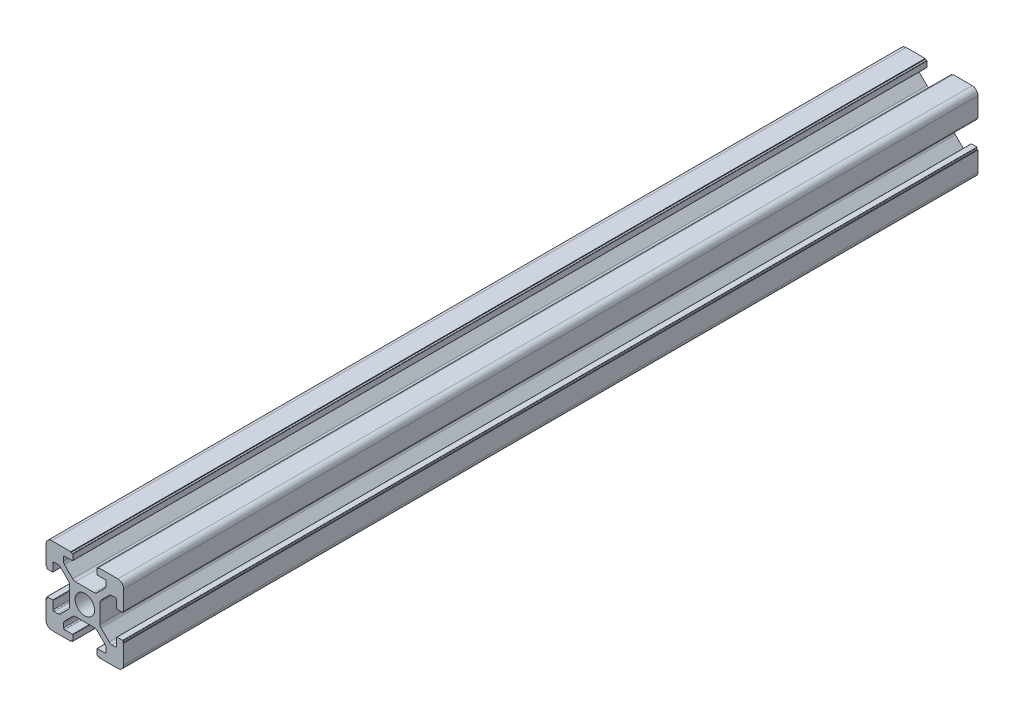
from build123d import *

# Parameters (mm, degrees)
SKETCH_1_R          = 2.5
EXTRUDE_1_DEPTH     = 220
FILLET_1_R          = 1.5
SKETCH_2_R          = 2
CUT_EXTRUDE_1_DEPTH = 21


with BuildPart() as part:
    # 草图1 → 凸台-拉伸1 (new body)
    with BuildSketch(Plane.XY):
        with BuildLine():
            Line((20, 13.6), (20, 20))
            Line((20, 20), (13.6, 20))
            Line((13.6, 20), (13.6, 19.8))
            Line((13.6, 19.8), (13.2, 19.8))
            ThreePointArc((13.2, 19.8), (13.129289322, 19.770710678), (13.1, 19.7))
            Line((13.1, 19.7), (13.1, 18.3))
            ThreePointArc((13.1, 18.3), (13.129289322, 18.229289322), (13.2, 18.2))
            Line((13.2, 18.2), (15.2, 18.2))
            ThreePointArc((15.2, 18.2), (15.412132034, 18.112132034), (15.5, 17.9))
            Line((15.5, 17.9), (15.5, 16.974873734))
            ThreePointArc((15.5, 16.974873734), (15.423879533, 16.592190302), (15.207106781, 16.267766953))
            Line((15.207106781, 16.267766953), (13.132233047, 14.192893219))
            ThreePointArc((13.132233047, 14.192893219), (12.807809698, 13.976120467), (12.425126266, 13.9))
            Line((12.425126266, 13.9), (7.574873734, 13.9))
            ThreePointArc((7.574873734, 13.9), (7.192190302, 13.976120467), (6.867766953, 14.192893219))
            Line((6.867766953, 14.192893219), (4.792893219, 16.267766953))
            ThreePointArc((4.792893219, 16.267766953), (4.576120467, 16.592190302), (4.5, 16.974873734))
            Line((4.5, 16.974873734), (4.5, 17.9))
            ThreePointArc((4.5, 17.9), (4.587867966, 18.112132034), (4.8, 18.2))
            Line((4.8, 18.2), (6.8, 18.2))
            ThreePointArc((6.8, 18.2), (6.870710678, 18.229289322), (6.9, 18.3))
            Line((6.9, 18.3), (6.9, 19.7))
            ThreePointArc((6.9, 19.7), (6.870710678, 19.770710678), (6.8, 19.8))
            Line((6.8, 19.8), (6.4, 19.8))
            Line((6.4, 19.8), (6.4, 20))
            Line((6.4, 20), (0, 20))
            Line((0, 20), (0, 13.6))
            Line((0, 13.6), (0.2, 13.6))
            Line((0.2, 13.6), (0.2, 13.2))
            ThreePointArc((0.2, 13.2), (0.229289322, 13.129289322), (0.3, 13.1))
            Line((0.3, 13.1), (1.7, 13.1))
            ThreePointArc((1.7, 13.1), (1.770710678, 13.129289322), (1.8, 13.2))
            Line((1.8, 13.2), (1.8, 15.2))
            ThreePointArc((1.8, 15.2), (1.887867966, 15.412132034), (2.1, 15.5))
            Line((2.1, 15.5), (3.025126266, 15.5))
            ThreePointArc((3.025126266, 15.5), (3.407809698, 15.423879533), (3.732233047, 15.207106781))
            Line((3.732233047, 15.207106781), (5.807106781, 13.132233047))
            ThreePointArc((5.807106781, 13.132233047), (6.023879533, 12.807809698), (6.1, 12.425126266))
            Line((6.1, 12.425126266), (6.1, 7.574873734))
            ThreePointArc((6.1, 7.574873734), (6.023879533, 7.192190302), (5.807106781, 6.867766953))
            Line((5.807106781, 6.867766953), (3.732233047, 4.792893219))
            ThreePointArc((3.732233047, 4.792893219), (3.407809698, 4.576120467), (3.025126266, 4.5))
            Line((3.025126266, 4.5), (2.1, 4.5))
            ThreePointArc((2.1, 4.5), (1.887867966, 4.587867966), (1.8, 4.8))
            Line((1.8, 4.8), (1.8, 6.8))
            ThreePointArc((1.8, 6.8), (1.770710678, 6.870710678), (1.7, 6.9))
            Line((1.7, 6.9), (0.3, 6.9))
            ThreePointArc((0.3, 6.9), (0.229289322, 6.870710678), (0.2, 6.8))
            Line((0.2, 6.8), (0.2, 6.4))
            Line((0.2, 6.4), (0, 6.4))
            Line((0, 6.4), (0, 0))
            Line((0, 0), (6.4, 0))
            Line((6.4, 0), (6.4, 0.2))
            Line((6.4, 0.2), (6.8, 0.2))
            ThreePointArc((6.8, 0.2), (6.870710678, 0.229289322), (6.9, 0.3))
            Line((6.9, 0.3), (6.9, 1.7))
            ThreePointArc((6.9, 1.7), (6.870710678, 1.770710678), (6.8, 1.8))
            Line((6.8, 1.8), (4.8, 1.8))
            ThreePointArc((4.8, 1.8), (4.587867966, 1.887867966), (4.5, 2.1))
            Line((4.5, 2.1), (4.5, 3.025126266))
            ThreePointArc((4.5, 3.025126266), (4.576120467, 3.407809698), (4.792893219, 3.732233047))
            Line((4.792893219, 3.732233047), (6.867766953, 5.807106781))
            ThreePointArc((6.867766953, 5.807106781), (7.192190302, 6.023879533), (7.574873734, 6.1))
            Line((7.574873734, 6.1), (12.425126266, 6.1))
            ThreePointArc((12.425126266, 6.1), (12.807809698, 6.023879533), (13.132233047, 5.807106781))
            Line((13.132233047, 5.807106781), (15.207106781, 3.732233047))
            ThreePointArc((15.207106781, 3.732233047), (15.423879533, 3.407809698), (15.5, 3.025126266))
            Line((15.5, 3.025126266), (15.5, 2.1))
            ThreePointArc((15.5, 2.1), (15.412132034, 1.887867966), (15.2, 1.8))
            Line((15.2, 1.8), (13.2, 1.8))
            ThreePointArc((13.2, 1.8), (13.129289322, 1.770710678), (13.1, 1.7))
            Line((13.1, 1.7), (13.1, 0.3))
            ThreePointArc((13.1, 0.3), (13.129289322, 0.229289322), (13.2, 0.2))
            Line((13.2, 0.2), (13.6, 0.2))
            Line((13.6, 0.2), (13.6, 0))
            Line((13.6, 0), (20, 0))
            Line((20, 0), (20, 6.4))
            Line((20, 6.4), (19.8, 6.4))
            Line((19.8, 6.4), (19.8, 6.8))
            ThreePointArc((19.8, 6.8), (19.770710678, 6.870710678), (19.7, 6.9))
            Line((19.7, 6.9), (18.3, 6.9))
            ThreePointArc((18.3, 6.9), (18.229289322, 6.870710678), (18.2, 6.8))
            Line((18.2, 6.8), (18.2, 4.8))
            ThreePointArc((18.2, 4.8), (18.112132034, 4.587867966), (17.9, 4.5))
            Line((17.9, 4.5), (16.974873734, 4.5))
            ThreePointArc((16.974873734, 4.5), (16.592190302, 4.576120467), (16.267766953, 4.792893219))
            Line((16.267766953, 4.792893219), (14.192893219, 6.867766953))
            ThreePointArc((14.192893219, 6.867766953), (13.976120467, 7.192190302), (13.9, 7.574873734))
            Line((13.9, 7.574873734), (13.9, 12.425126266))
            ThreePointArc((13.9, 12.425126266), (13.976120467, 12.807809698), (14.192893219, 13.132233047))
            Line((14.192893219, 13.132233047), (16.267766953, 15.207106781))
            ThreePointArc((16.267766953, 15.207106781), (16.592190302, 15.423879533), (16.974873734, 15.5))
            Line((16.974873734, 15.5), (17.9, 15.5))
            ThreePointArc((17.9, 15.5), (18.112132034, 15.412132034), (18.2, 15.2))
            Line((18.2, 15.2), (18.2, 13.2))
            ThreePointArc((18.2, 13.2), (18.229289322, 13.129289322), (18.3, 13.1))
            Line((18.3, 13.1), (19.7, 13.1))
            ThreePointArc((19.7, 13.1), (19.770710678, 13.129289322), (19.8, 13.2))
            Line((19.8, 13.2), (19.8, 13.6))
            Line((19.8, 13.6), (20, 13.6))
        make_face()
        with Locations((10, 10)):
            Circle(SKETCH_1_R, mode=Mode.SUBTRACT)
    extrude(amount=EXTRUDE_1_DEPTH)

    # 圆角1
    fillet_1_edges = [part.edges().sort_by_distance(p)[0] for p in [
        (0, 0, 110),
        (0, 20, 110),
        (20, 20, 110),
        (20, 0, 110),
    ]]
    fillet(fillet_1_edges, radius=FILLET_1_R)

    # 草图2 → 切除-拉伸1 (cut, through all)
    with BuildSketch(Plane.XZ):
        with Locations((10, 110)):
            Circle(SKETCH_2_R)
        with Locations((10, 180)):
            Circle(SKETCH_2_R)
        with Locations((10, 40)):
            Circle(SKETCH_2_R)
    extrude(amount=-CUT_EXTRUDE_1_DEPTH, mode=Mode.SUBTRACT)


solid = part.part
